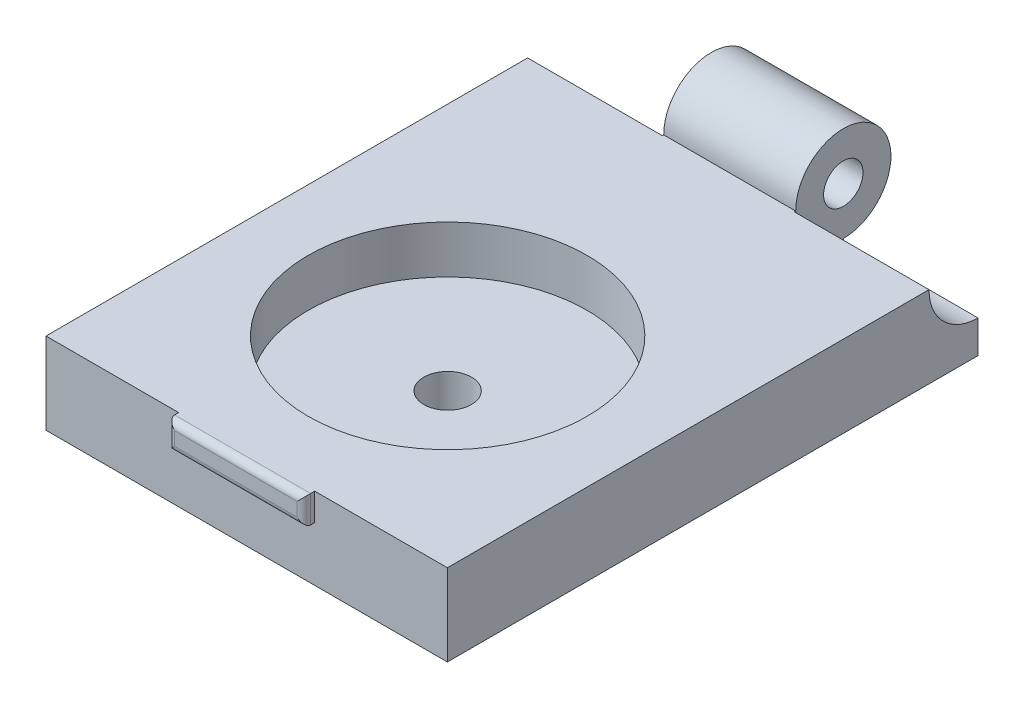
from build123d import *

# Parameters (mm, degrees)
SKETCH2_W           = 29.5
SKETCH2_H           = 39
BOSS_EXTRUDE1_DEPTH = 6
SKETCH3_R           = 10.25
CUT_EXTRUDE1_DEPTH  = 3.5
SKETCH4_R           = 1.75
CUT_EXTRUDE2_DEPTH  = 3.5
SKETCH5_R           = 3.6
CUT_EXTRUDE3_DEPTH  = 9.9
SKETCH6_R           = 3.6
CUT_EXTRUDE4_DEPTH  = 9.9
SKETCH7_R           = 3.5
BOSS_EXTRUDE2_DEPTH = 9.7
CUT_EXTRUDE5_REACH  = 21.6
SKETCH8_R           = 1.45
SKETCH9_W           = 10
SKETCH9_H           = 2
BOSS_EXTRUDE3_DEPTH = 0.8
FILLET1_R           = 0.5


with BuildPart() as part:
    # Sketch2 → Boss-Extrude1 (new body)
    with BuildSketch(Plane(origin=(0, 0, 0), x_dir=(1, 0, 0), z_dir=(0, 1, 0))):
        with Locations((3.309391497, -2.30838063)):
            Rectangle(SKETCH2_W, SKETCH2_H)
    extrude(amount=BOSS_EXTRUDE1_DEPTH)

    # Sketch3 → Cut-Extrude1 (cut)
    with BuildSketch(Plane(origin=(0, 6, 0), x_dir=(1, 0, 0), z_dir=(0, 1, 0))):
        with Locations((3.309391497, -7.038449274)):
            Circle(SKETCH3_R)
    extrude(amount=-CUT_EXTRUDE1_DEPTH, mode=Mode.SUBTRACT)

    # Sketch4 → Cut-Extrude2 (cut, through all)
    with BuildSketch(Plane(origin=(0, 2.5, 0), x_dir=(1, 0, 0), z_dir=(0, 1, 0))):
        with Locations((3.309391497, -7.038449274)):
            Circle(SKETCH4_R)
    extrude(amount=-CUT_EXTRUDE2_DEPTH, mode=Mode.SUBTRACT)

    # Sketch5 → Cut-Extrude3 (cut)
    with BuildSketch(Plane(origin=(18.059391497, 0, 0), x_dir=(0, 0, -1), z_dir=(1, 0, 0))):
        with Locations((17.19161937, 6)):
            Circle(SKETCH5_R)
    extrude(amount=-CUT_EXTRUDE3_DEPTH, mode=Mode.SUBTRACT)

    # Sketch6 → Cut-Extrude4 (cut)
    with BuildSketch(Plane.ZY.offset(11.440608503)):
        with Locations((-17.19161937, 6)):
            Circle(SKETCH6_R)
    extrude(amount=-CUT_EXTRUDE4_DEPTH, mode=Mode.SUBTRACT)

    # Sketch7 → Boss-Extrude2 (add)
    with BuildSketch(Plane.ZY.offset(1.540608503)):
        with Locations((-17.19161937, 6)):
            Circle(SKETCH7_R)
    extrude(amount=-BOSS_EXTRUDE2_DEPTH)

    # Sketch8 → Cut-Extrude5 (cut, up to next)
    with BuildSketch(Plane(origin=(8.159391497, 0, 0), x_dir=(0, 0, -1), z_dir=(1, 0, 0)), mode=Mode.PRIVATE) as cut_extrude5_sk1:
        with Locations((17.19161937, 6)):
            Circle(SKETCH8_R)
    cut_extrude5_tool1 = extrude(cut_extrude5_sk1.sketch, amount=-CUT_EXTRUDE5_REACH, mode=Mode.PRIVATE) & part.part
    add(cut_extrude5_tool1.solids().sort_by_distance((8.159391, 6, -17.191619))[0], mode=Mode.SUBTRACT)

    # Sketch9 → Boss-Extrude3 (add)
    with BuildSketch(Plane.XY.offset(21.80838063)):
        with Locations((3.309391497, 5)):
            Rectangle(SKETCH9_W, SKETCH9_H)
    extrude(amount=BOSS_EXTRUDE3_DEPTH)

    # Fillet1
    fillet1_edges = [part.edges().sort_by_distance(p)[0] for p in [
        (-1.690608503, 5, 22.60838063),
        (3.309391497, 4, 22.60838063),
        (8.309391497, 5, 22.60838063),
        (3.309391497, 6, 22.60838063),
    ]]
    fillet(fillet1_edges, radius=FILLET1_R)


solid = part.part
